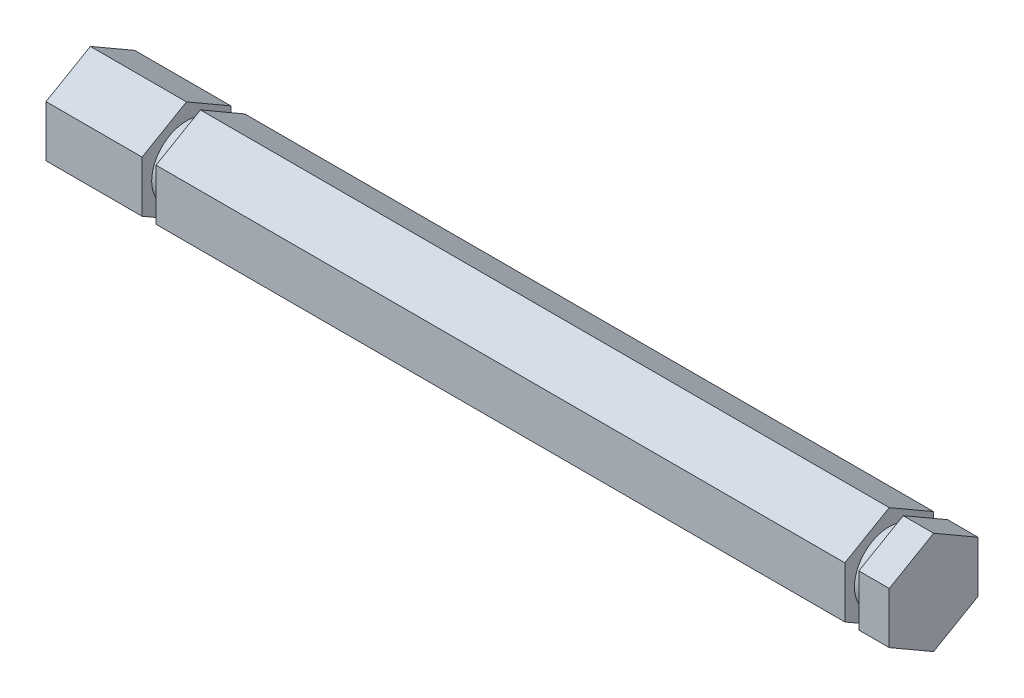
from build123d import *

# Parameters (mm, degrees)
BOSS_EXTRUDE1_DEPTH = 120.65
SKETCH2_W           = 2
SKETCH2_H           = 2.353948419


with BuildPart() as part:
    # Sketch1 → Boss-Extrude1 (new body)
    with BuildSketch(Plane(origin=(0, 0, 0), x_dir=(0, 0, -1), z_dir=(1, 0, 0))):
        Polygon((0, 7.332348419), (-6.35, 3.666174209), (-6.35, -3.666174209), (0, -7.332348419), (6.35, -3.666174209), (6.35, 3.666174209), align=None)
    extrude(amount=BOSS_EXTRUDE1_DEPTH)

    # Sketch2 → Cut-Revolve1 (revolve, cut)
    with BuildSketch(Plane.XY):
        with Locations((115.3, 6.15537421)):
            Rectangle(SKETCH2_W, SKETCH2_H)
        with Locations((14.748, 6.15537421)):
            Rectangle(SKETCH2_W, SKETCH2_H)
    revolve(axis=Axis((0, 0, 0), (1, 0, 0)), mode=Mode.SUBTRACT)


solid = part.part
